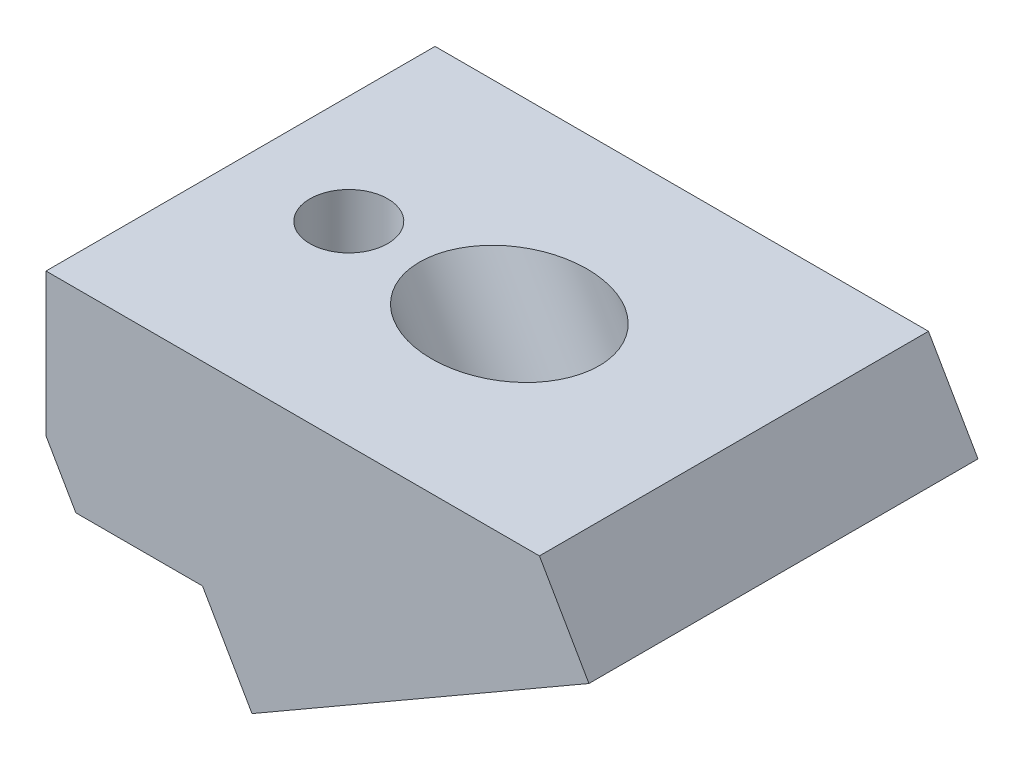
from build123d import *

# Parameters (mm, degrees)
ESBO_O1_W                  = 30
ESBO_O1_H                  = 30
RESSALTO_EXTRUS_O1_DEPTH   = 22.775
CORTE_EXTRUS_O1_DEPTH      = 41.542577927
ESBO_O3_OUTSIDE_W          = 48.998
ESBO_O3_OUTSIDE_H          = 41.63
ESBO_O3_OUTSIDE_W_2        = 30
ESBO_O3_OUTSIDE_H_2        = 30
CORTE_EXTRUS_O2_DEPTH      = 30.010251575
RESSALTO_EXTRUS_O2_DEPTH   = 30
ESBO_O5_R                  = 3.95
CORTE_EXTRUS_O3_DEPTH      = 32.012511133
CORTE_EXTRUS_O5_START      = -8
ESBO_O8_R                  = 6
CORTE_EXTRUS_O5_DEPTH      = 25
ESBO_O9_R                  = 3.95
CORTE_EXTRUS_O6_DEPTH      = 10
RESSALTO_EXTRUS_O3_DEPTH   = 15
ESBO_O11_W                 = 30
ESBO_O11_H                 = 15
RESSALTO_EXTRUS_O4_DEPTH   = 10
ESBO_O9_2_R                = 3.95
CORTE_EXTRUS_O7_DEPTH      = 30
ESBO_O12_R                 = 5.35
CORTE_EXTRUS_O8_DEPTH      = 10
CORTE_EXTRUS_O8_DEPTH_BACK = 3.5
ESBO_O13_W                 = 11.908257902
ESBO_O13_H                 = 30
CORTE_EXTRUS_O9_DEPTH      = 23.5
ESBO_O14_R                 = 3.95
ESBO_O14_R_2               = 3
RESSALTO_EXTRUS_O5_DEPTH   = 11.5
CORTE_EXTRUS_O10_DEPTH     = 30


with BuildPart() as part:
    # Esboço1 → Ressalto-extrusão1 (new body)
    with BuildSketch(Plane(origin=(0, 0, 0), x_dir=(1, 0, 0), z_dir=(0, 1, 0))):
        Rectangle(ESBO_O1_W, ESBO_O1_H)
    extrude(amount=RESSALTO_EXTRUS_O1_DEPTH)

    # Esboço2 → Corte-extrusão1 (cut, through all)
    with BuildSketch(Plane.XY.offset(15)):
        Polygon((-15, 0), (15, 17.320508076), (15, 0), align=None)
    extrude(amount=-CORTE_EXTRUS_O1_DEPTH, mode=Mode.SUBTRACT)

    # Esboço3 outside → Corte-extrusão2 (cut, through all)
    with BuildSketch(Plane(origin=(-3.75, 6.495190528, 0), x_dir=(0.8660254037844378, 0.5000000000000017, 0), z_dir=(0.5000000000000016, -0.8660254037844377, 0))):
        with Locations((5.694, 0)):
            Rectangle(ESBO_O3_OUTSIDE_W, ESBO_O3_OUTSIDE_H)
        with Locations((4.330127019, 0)):
            Rectangle(ESBO_O3_OUTSIDE_W_2, ESBO_O3_OUTSIDE_H_2, mode=Mode.SUBTRACT)
    extrude(amount=-CORTE_EXTRUS_O2_DEPTH, mode=Mode.SUBTRACT)

    # Esboço4 → Ressalto-extrusão2 (add)
    with BuildSketch(Plane.XY.offset(15)):
        Polygon((-25.469660456, 22.775), (-15, 4.641016151), (-15, 22.775), align=None)
    extrude(amount=-RESSALTO_EXTRUS_O2_DEPTH)

    # Esboço5 → Corte-extrusão3 (cut, through all)
    with BuildSketch(Plane(origin=(-3.75, 6.495190528, 0), x_dir=(-0.8660254037844379, -0.5000000000000013, 0), z_dir=(0.5000000000000013, -0.8660254037844379, 0))):
        with Locations(Location((-4.330131096, -4.077e-06, 0), (0, 0, 180))):
            Circle(ESBO_O5_R)
    extrude(amount=-CORTE_EXTRUS_O3_DEPTH, mode=Mode.SUBTRACT)

    # Esboço8 → Corte-extrusão5 (cut)
    with BuildSketch(Plane(origin=(-3.75, 6.495190528, 0), x_dir=(0.8660254037844379, 0.5000000000000013, 0), z_dir=(0.5000000000000013, -0.8660254037844379, 0)).offset(CORTE_EXTRUS_O5_START)):
        with Locations((4.330131096, 4.077e-06)):
            Circle(ESBO_O8_R)
    extrude(amount=-CORTE_EXTRUS_O5_DEPTH, mode=Mode.SUBTRACT)

    # Esboço9 → Corte-extrusão6 (cut)
    with BuildSketch(Plane(origin=(0, 22.775, 0), x_dir=(1, 0, 0), z_dir=(0, 1, 0))):
        with Locations(Location((-20.527350903, 0, 0), (0, 0, 270))):
            Circle(ESBO_O9_R)
    extrude(amount=-CORTE_EXTRUS_O6_DEPTH, mode=Mode.SUBTRACT)



with BuildPart() as body_2:
    # Esboço10 → Ressalto-extrusão3 (new body)
    with BuildSketch(Plane(origin=(0, 22.775, 0), x_dir=(1, 0, 0), z_dir=(0, 1, 0))):
        Polygon((-25.469660456, 15), (-40.785608805, 15), (-40.785608805, -15), (-25.469660456, -15), (-25.469660456, -3.937347933), (-25.469660456, 3.937339779), align=None)
    extrude(amount=-RESSALTO_EXTRUS_O3_DEPTH)


with BuildPart() as part_1:
    add(part.part)

    add(body_2.part)  # Ressalto-extrusão4 merges body 2
    # Esboço11 → Ressalto-extrusão4 (add)
    with BuildSketch(Plane(origin=(-25.469660456, 0, 0), x_dir=(0, 0, -1), z_dir=(1, 0, 0))):
        with Locations((0, 15.275)):
            Rectangle(ESBO_O11_W, ESBO_O11_H)
    extrude(amount=RESSALTO_EXTRUS_O4_DEPTH)

    # Esboço9<2> → Corte-extrusão7 (cut)
    with BuildSketch(Plane(origin=(0, 22.775, 0), x_dir=(1, 0, 0), z_dir=(0, 1, 0))):
        with Locations(Location((-20.527350903, 0, 0), (0, 0, 270))):
            Circle(ESBO_O9_2_R)
    extrude(amount=-CORTE_EXTRUS_O7_DEPTH, mode=Mode.SUBTRACT)

    # Esboço12 → Corte-extrusão8 (cut, two sides)
    with BuildSketch(Plane.XZ.offset(-7.775)) as corte_extrus_o8_sk:
        with Locations(Location((-20.527350903, 0, 0), (0, 0, 45.977333205))):
            Circle(ESBO_O12_R)
    extrude(amount=CORTE_EXTRUS_O8_DEPTH, mode=Mode.SUBTRACT)
    extrude(corte_extrus_o8_sk.sketch, amount=-CORTE_EXTRUS_O8_DEPTH_BACK, mode=Mode.SUBTRACT)

    # Esboço13 → Corte-extrusão9 (cut)
    with BuildSketch(Plane.XZ.offset(-7.775)):
        with Locations((-34.831479854, 0)):
            Rectangle(ESBO_O13_W, ESBO_O13_H)
    extrude(amount=-CORTE_EXTRUS_O9_DEPTH, mode=Mode.SUBTRACT)

    # Esboço14 → Ressalto-extrusão5 (add)
    with BuildSketch(Plane.XZ.offset(-11.275)):
        with Locations((-20.527350903, 0)):
            Circle(ESBO_O14_R)
        with Locations(Location((-20.527350903, 0, 0), (0, 0, 270))):
            Circle(ESBO_O14_R_2, mode=Mode.SUBTRACT)
    extrude(amount=-RESSALTO_EXTRUS_O5_DEPTH)

    # Esboço15 → Corte-extrusão10 (cut)
    with BuildSketch(Plane.XY.offset(15)):
        Polygon((-38.655450544, 28.698110147), (-22.922361913, 1.447601278), (-38.655450544, 1.447601278), align=None)
    extrude(amount=-CORTE_EXTRUS_O10_DEPTH, mode=Mode.SUBTRACT)


solid = part_1.part
